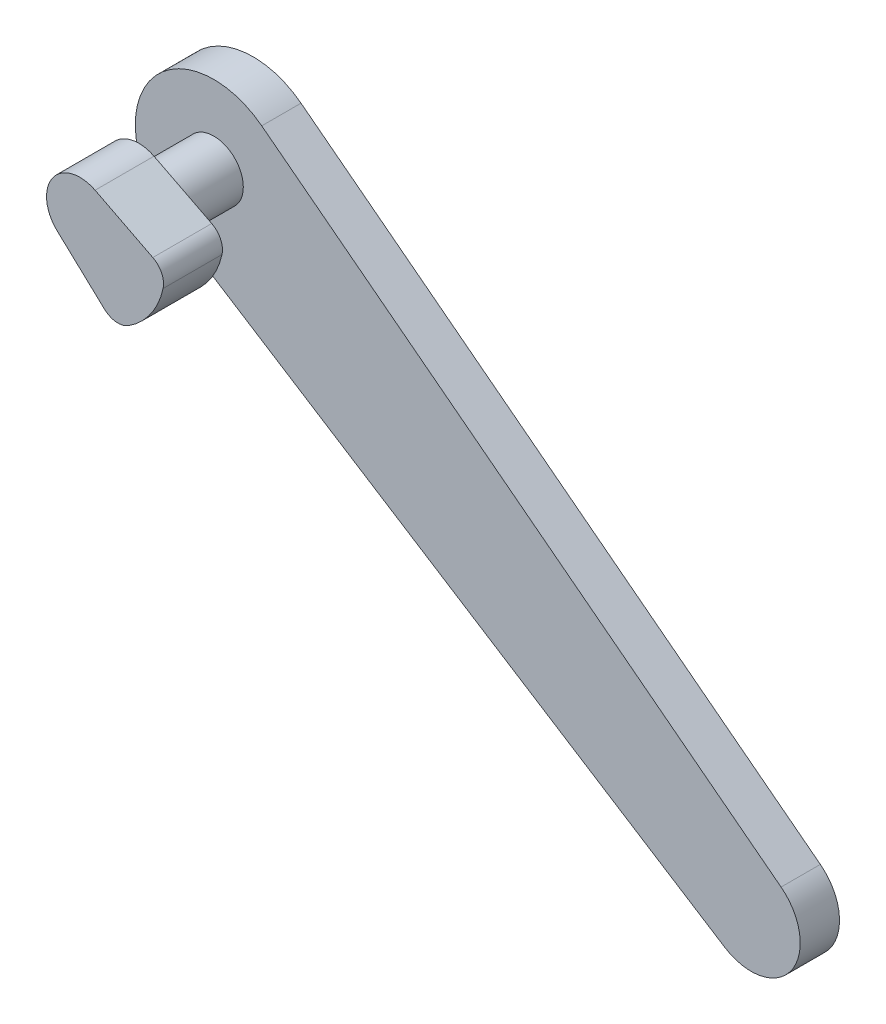
from build123d import *

# Parameters (mm, degrees)
EXTRUDE_1_DEPTH = 3
SKETCH_1_3_R    = 1.5
EXTRUDE_2_DEPTH = 3
EXTRUDE_3_DEPTH = 2


with BuildPart() as part:
    # 草图1 → 凸台-拉伸1 (new body)
    with BuildSketch(Plane.XY):
        with BuildLine():
            ThreePointArc((-0.047368195, 2.088287527), (-2.21171052, 1.548656378), (-1.978549256, -0.669724856))
            Line((-1.978549256, -0.669724856), (0.434917959, -2.920319445))
            ThreePointArc((0.434917959, -2.920319445), (1.024622501, -3.18469756), (1.652873302, -3.033211035))
            ThreePointArc((1.652873302, -3.033211035), (2.785653548, -1.950535613), (3.41560199, -0.515773572))
            ThreePointArc((3.41560199, -0.515773572), (3.343078331, 0.126400512), (2.892953335, 0.590118878))
            Line((2.892953335, 0.590118878), (-0.047368195, 2.088287527))
        make_face()
    extrude(amount=EXTRUDE_1_DEPTH)

    # 草图1<3> → 凸台-拉伸2 (add)
    with BuildSketch(Plane.XY):
        Circle(SKETCH_1_3_R)
    extrude(amount=-EXTRUDE_2_DEPTH)

    # 草图2 → 凸台-拉伸3 (add)
    with BuildSketch(Plane(origin=(0, 0, -3), x_dir=(-1, 0, 0), z_dir=(0, 0, -1))):
        with BuildLine():
            Line((-2.439141124, 3.170266641), (-28.884678079, -17.176412053))
            ThreePointArc((-28.884678079, -17.176412053), (-29.408094987, -20.591769795), (-26.019689394, -21.268039933))
            Line((-26.019689394, -21.268039933), (2.144840772, -3.376337966))
            ThreePointArc((2.144840772, -3.376337966), (3.276608177, 2.294305745), (-2.439141124, 3.170266641))
        make_face()
    extrude(amount=EXTRUDE_3_DEPTH)


solid = part.part
